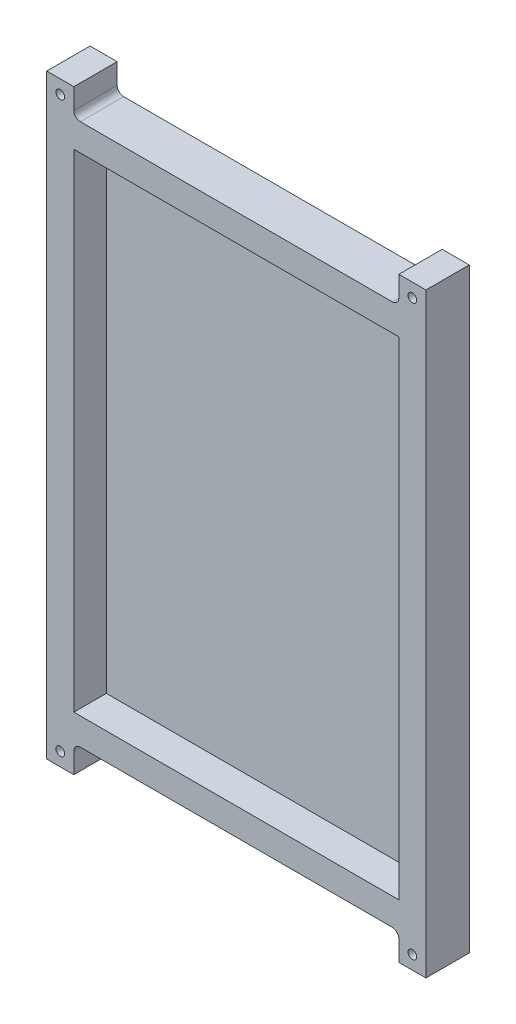
from build123d import *

# Parameters (mm, degrees)
BOSS_EXTRUDE1_DEPTH = 4
SKETCH2_W           = 120
SKETCH2_H           = 180
BOSS_EXTRUDE2_DEPTH = 12
SKETCH3_R           = 1.6
CUT_EXTRUDE1_DEPTH  = 12


with BuildPart() as part:
    # Sketch1 → Boss-Extrude1 (new body)
    with BuildSketch(Plane(origin=(0, 0, 0), x_dir=(0, 1, 0), z_dir=(0, 0, 1))):
        with BuildLine():
            Line((-10, 2.4), (-10, 117.6))
            ThreePointArc((-10, 117.6), (-10.702943725, 119.297056275), (-12.4, 120))
            Line((-12.4, 120), (-20, 120))
            Line((-20, 120), (-20, 130))
            Line((-20, 130), (-10, 130))
            Line((-10, 130), (190, 130))
            Line((190, 130), (200, 130))
            Line((200, 130), (200, 120))
            Line((200, 120), (192.4, 120))
            ThreePointArc((192.4, 120), (190.702943725, 119.297056275), (190, 117.6))
            Line((190, 117.6), (190, 2.4))
            ThreePointArc((190, 2.4), (190.702943725, 0.702943725), (192.4, 0))
            Line((192.4, 0), (200, 0))
            Line((200, 0), (200, -10))
            Line((200, -10), (190, -10))
            Line((190, -10), (-10, -10))
            Line((-10, -10), (-20, -10))
            Line((-20, -10), (-20, 0))
            Line((-20, 0), (-12.4, 0))
            ThreePointArc((-12.4, 0), (-10.702943725, 0.702943725), (-10, 2.4))
        make_face()
    extrude(amount=BOSS_EXTRUDE1_DEPTH)

    # Sketch2 → Boss-Extrude2 (add)
    with BuildSketch(Plane.XY.offset(4)):
        with BuildLine():
            Line((10, -20), (10, 200))
            Line((10, 200), (0, 200))
            Line((0, 200), (0, 192.4))
            ThreePointArc((0, 192.4), (-0.702943725, 190.702943725), (-2.4, 190))
            Line((-2.4, 190), (-117.6, 190))
            ThreePointArc((-117.6, 190), (-119.297056275, 190.702943725), (-120, 192.4))
            Line((-120, 192.4), (-120, 200))
            Line((-120, 200), (-130, 200))
            Line((-130, 200), (-130, -20))
            Line((-130, -20), (-120, -20))
            Line((-120, -20), (-120, -12.4))
            ThreePointArc((-120, -12.4), (-119.297056275, -10.702943725), (-117.6, -10))
            Line((-117.6, -10), (-2.4, -10))
            ThreePointArc((-2.4, -10), (-0.702943725, -10.702943725), (0, -12.4))
            Line((0, -12.4), (0, -20))
            Line((0, -20), (10, -20))
        make_face()
        with Locations((-60, 90)):
            Rectangle(SKETCH2_W, SKETCH2_H, mode=Mode.SUBTRACT)
    extrude(amount=BOSS_EXTRUDE2_DEPTH)

    # Sketch3 → Cut-Extrude1 (cut)
    with BuildSketch(Plane.XY.offset(16)):
        with Locations((-125, 195)):
            Circle(SKETCH3_R)
        with Locations((5, 195)):
            Circle(SKETCH3_R)
        with Locations((5, -15)):
            Circle(SKETCH3_R)
        with Locations((-125, -15)):
            Circle(SKETCH3_R)
    extrude(amount=-CUT_EXTRUDE1_DEPTH, mode=Mode.SUBTRACT)


solid = part.part
